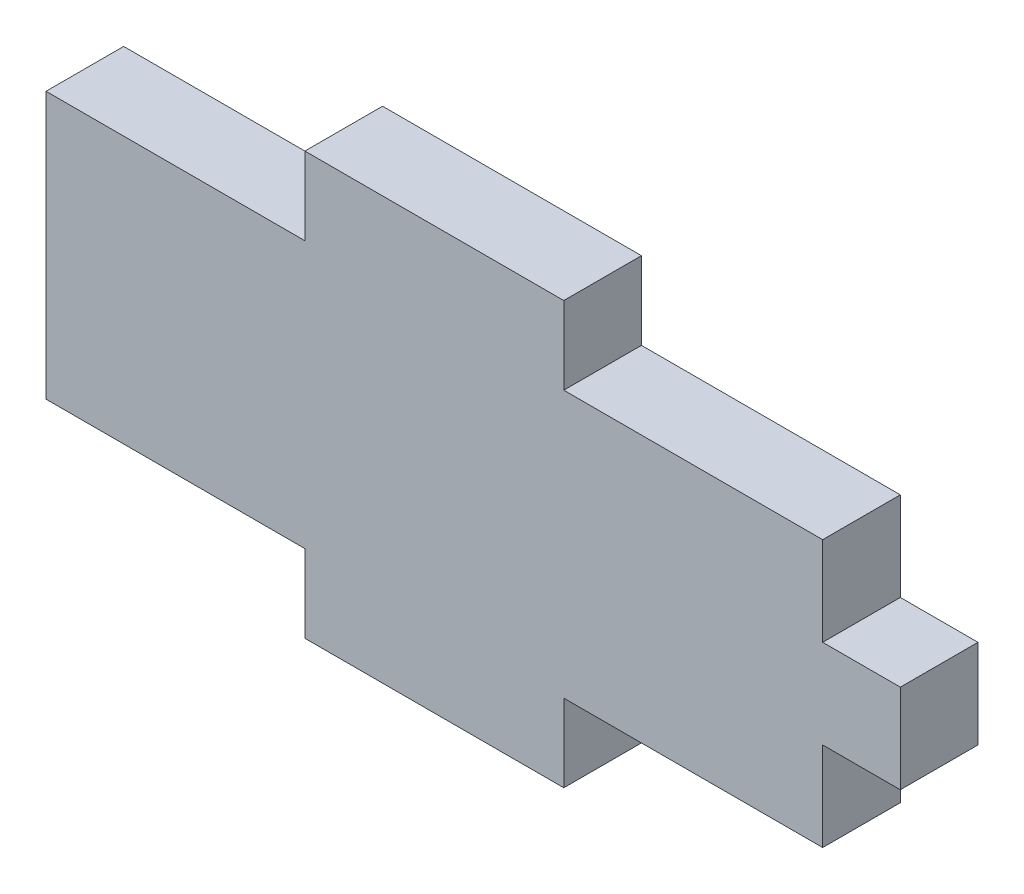
from build123d import *

# Parameters (mm, degrees)
BOSS_EXTRUDE1_DEPTH = 3


with BuildPart() as part:
    # Sketch1 → Boss-Extrude1 (new body)
    with BuildSketch(Plane.XY):
        Polygon((0, 0), (10, 0), (10, -3), (20, -3), (20, 0), (30, 0), (30, 3.433333337), (33, 3.433333337), (33, 6.866666667), (30, 6.866666667), (30, 10.3), (20, 10.3), (20, 13.3), (10, 13.3), (10, 10.3), (0, 10.3), align=None)
    extrude(amount=BOSS_EXTRUDE1_DEPTH)


solid = part.part
